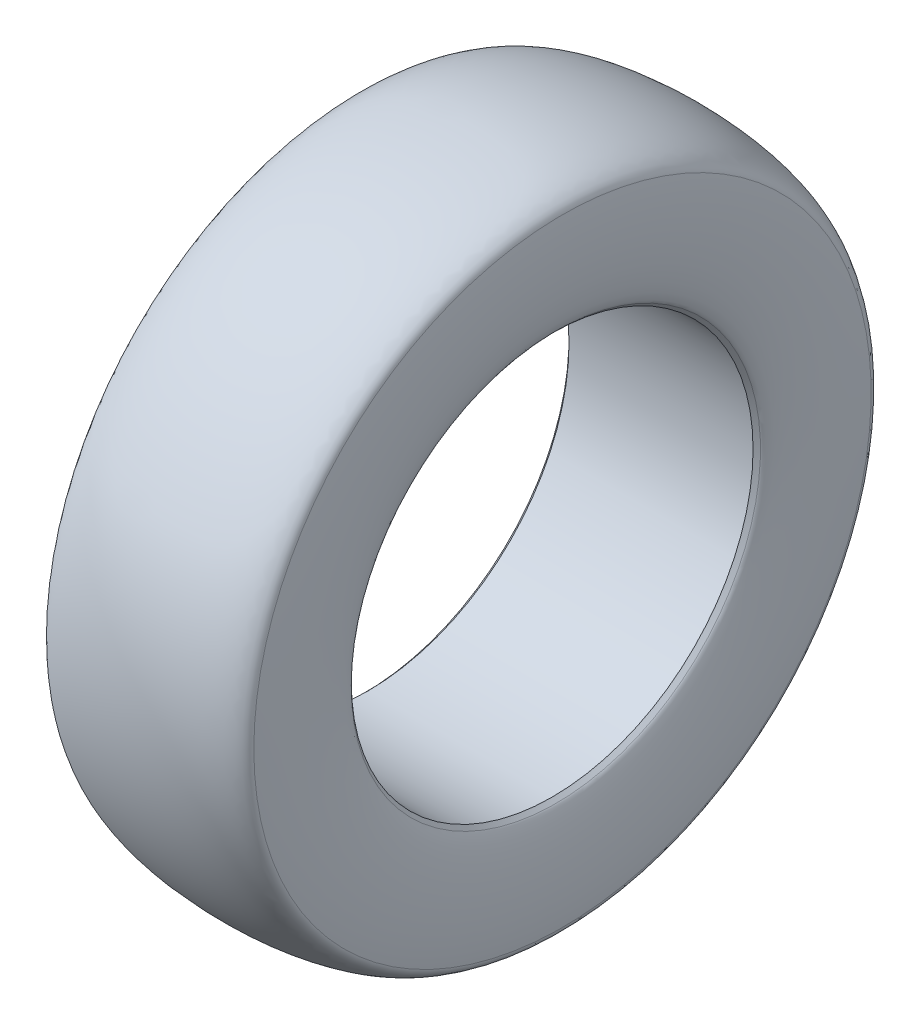
from build123d import *


with BuildPart() as part:
    # Sketch1 → Revolve1 (revolve)
    with BuildSketch(Plane.XY):
        with BuildLine():
            Line((-111.669743879, 243.84), (111.669743879, 243.84))
            Line((111.669743879, 243.84), (116.159871939, 248.330128061))
            add(Edge.make_bspline(
                [(116.159871939, 248.330128061), (137.810721683, 269.980977804), (124.216998202, 374.580726901)],
                knots=[3.304797887, 3.304797887, 3.304797887, 5.380517095, 5.380517095, 5.380517095], degree=2, weights=[1, 0.508064983, 1]))
            add(Edge.make_bspline(
                [(124.216998202, 374.580726901), (120.081783695, 406.4), (0, 406.4), (-120.081783695, 406.4), (-124.216998202, 374.580726901)],
                knots=[3.176036115, 3.176036115, 3.176036115, 4.71238898, 4.71238898, 6.248741846, 6.248741846, 6.248741846], degree=2, weights=[1, 0.719178925, 1, 0.719178925, 1]))
            add(Edge.make_bspline(
                [(-124.216998202, 374.580726901), (-137.810721683, 269.980977804), (-116.159871939, 248.330128061)],
                knots=[0.902668212, 0.902668212, 0.902668212, 2.97838742, 2.97838742, 2.97838742], degree=2, weights=[1, 0.508064983, 1]))
            Line((-116.159871939, 248.330128061), (-111.669743879, 243.84))
        make_face()
    revolve(axis=Axis((-1000, 0, 0), (1, 0, 0)))


solid = part.part
